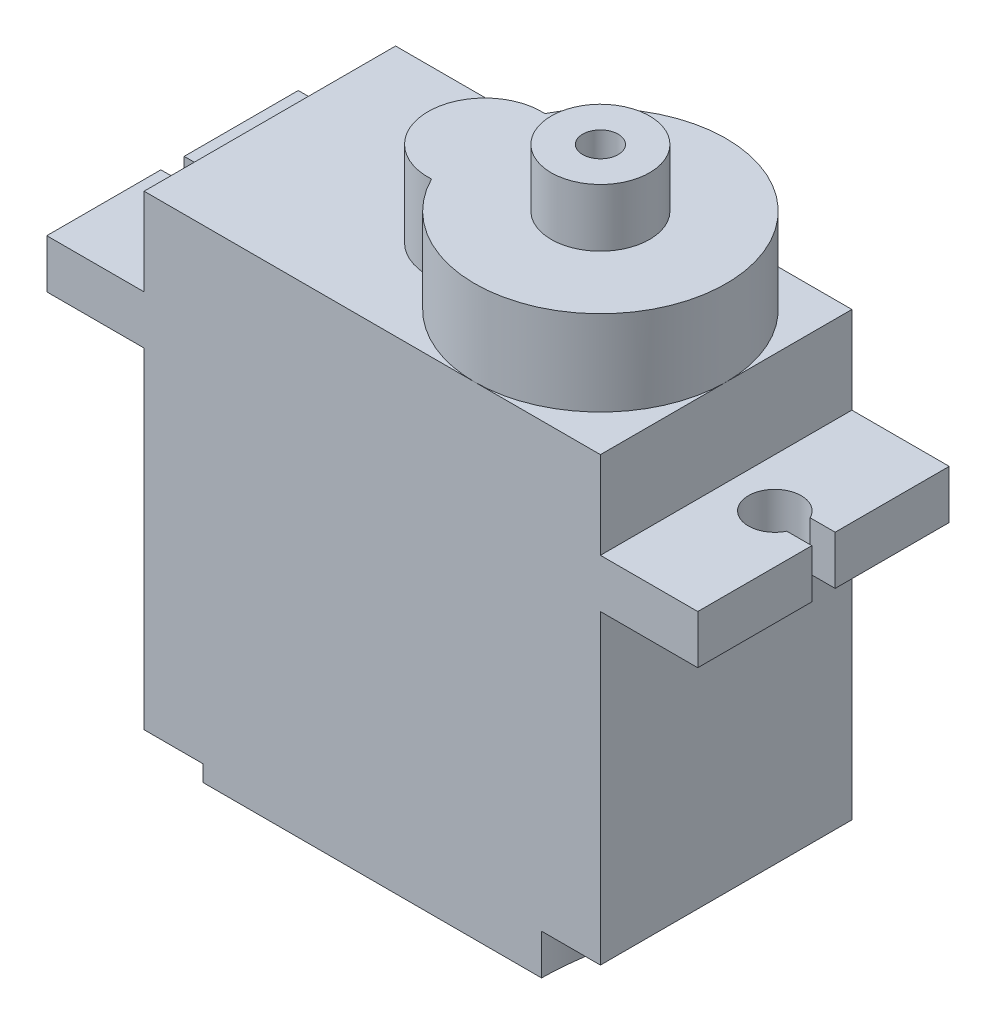
from build123d import *

# Parameters (mm, degrees)
SALIENTE_EXTRUIR1_DEPTH = 6.2
SALIENTE_EXTRUIR2_DEPTH = 4.2
CORTAR_EXTRUIR1_REACH   = 28.006
CORTAR_EXTRUIR3_DEPTH   = 0.8
CROQUIS4_5_W            = 1.5
CROQUIS4_5_H            = 3.75
CORTAR_EXTRUIR4_DEPTH   = 2
CORTAR_EXTRUIR5_DEPTH   = 26.895414652
CROQUIS7_R              = 2.425
CROQUIS7_R_2            = 0.875
SALIENTE_EXTRUIR4_DEPTH = 2.85


with BuildPart() as part:
    # Croquis1 → Saliente-Extruir1 (new, symmetric)
    with BuildSketch(Plane.XY):
        Polygon((-11.25, 5.2), (-11.25, -11.9), (11.25, -11.9), (11.25, 5.2), (16.05, 5.2), (16.05, 7.6), (11.25, 7.6), (11.25, 11.9), (-11.25, 11.9), (-11.25, 7.6), (-16.05, 7.6), (-16.05, 5.2), align=None)
    extrude(amount=SALIENTE_EXTRUIR1_DEPTH, both=True)

    # Croquis2 → Saliente-Extruir2 (add)
    with BuildSketch(Plane(origin=(0, 11.9, 0), x_dir=(1, 0, 0), z_dir=(0, 1, 0))):
        with BuildLine():
            ThreePointArc((-0.484210526, -2.79508745), (11.25, 0), (-0.484210526, 2.79508745))
            ThreePointArc((-0.484210526, 2.79508745), (-3.45, 0), (-0.484210526, -2.79508745))
        make_face()
    extrude(amount=SALIENTE_EXTRUIR2_DEPTH)

    # Croquis3 → Cortar-Extruir1 (cut, up to next)
    with BuildSketch(Plane(origin=(0, 7.6, 0), x_dir=(1, 0, 0), z_dir=(0, 1, 0)), mode=Mode.PRIVATE) as cortar_extruir1_sk1:
        with BuildLine():
            Line((16.05, 0.575), (14.815922382, 0.575))
            ThreePointArc((14.815922382, 0.575), (12.35, 0), (14.815922382, -0.575))
            Line((14.815922382, -0.575), (16.05, -0.575))
            Line((16.05, -0.575), (16.05, 0.575))
        make_face()
    cortar_extruir1_tool1 = extrude(cortar_extruir1_sk1.sketch, amount=-CORTAR_EXTRUIR1_REACH, mode=Mode.PRIVATE) & part.part
    # Croquis3 → Cortar-Extruir1 (cut, up to next)
    with BuildSketch(Plane(origin=(0, 7.6, 0), x_dir=(1, 0, 0), z_dir=(0, 1, 0)), mode=Mode.PRIVATE) as cortar_extruir1_sk2:
        with BuildLine():
            Line((-16.05, 0.575), (-14.815922382, 0.575))
            ThreePointArc((-14.815922382, 0.575), (-12.35, 0), (-14.815922382, -0.575))
            Line((-14.815922382, -0.575), (-16.05, -0.575))
            Line((-16.05, -0.575), (-16.05, 0.575))
        make_face()
    cortar_extruir1_tool2 = extrude(cortar_extruir1_sk2.sketch, amount=-CORTAR_EXTRUIR1_REACH, mode=Mode.PRIVATE) & part.part
    add(cortar_extruir1_tool1.solids().sort_by_distance((14.012834, 7.6, 0))[0], mode=Mode.SUBTRACT)
    add(cortar_extruir1_tool2.solids().sort_by_distance((-14.012834, 7.6, 0))[0], mode=Mode.SUBTRACT)

    # Croquis4 → Cortar-Extruir3 (cut)
    with BuildSketch(Plane.XZ.offset(11.9)):
        with BuildLine():
            Line((-11.25, 6.2), (-11.25, 3.3))
            ThreePointArc((-11.25, 3.3), (-9.199390335, 4.149390335), (-8.35, 6.2))
            Line((-8.35, 6.2), (-11.25, 6.2))
        make_face()
        with BuildLine():
            ThreePointArc((-8.35, -6.2), (-9.199390335, -4.149390335), (-11.25, -3.3))
            Line((-11.25, -3.3), (-11.25, -6.2))
            Line((-11.25, -6.2), (-8.35, -6.2))
        make_face()
    extrude(amount=-CORTAR_EXTRUIR3_DEPTH, mode=Mode.SUBTRACT)

    # Croquis4_5 → Cortar-Extruir4 (cut)
    with BuildSketch(Plane.XZ.offset(11.9)):
        with BuildLine():
            Line((11.25, 6.2), (8.35, 6.2))
            ThreePointArc((8.35, 6.2), (9.199390335, 4.149390335), (11.25, 3.3))
            Line((11.25, 3.3), (11.25, 6.2))
        make_face()
        with BuildLine():
            ThreePointArc((11.25, -3.3), (9.199390335, -4.149390335), (8.35, -6.2))
            Line((8.35, -6.2), (11.25, -6.2))
            Line((11.25, -6.2), (11.25, -3.3))
        make_face()
        with Locations((10.5, 0)):
            Rectangle(CROQUIS4_5_W, CROQUIS4_5_H)
    extrude(amount=-CORTAR_EXTRUIR4_DEPTH, mode=Mode.SUBTRACT)

    # Croquis6 → Cortar-Extruir5 (cut, through all)
    with BuildSketch(Plane(origin=(0, 0, -6.2), x_dir=(-1, 0, 0), z_dir=(0, 0, -1))):
        Polygon((-11.25, -9.9), (-8.35, -11.9), (-11.25, -11.9), align=None)
    extrude(amount=-CORTAR_EXTRUIR5_DEPTH, mode=Mode.SUBTRACT)

    # Croquis7 → Saliente-Extruir4 (add)
    with BuildSketch(Plane(origin=(0, 16.1, 0), x_dir=(1, 0, 0), z_dir=(0, 1, 0))):
        with Locations((5.05, 0)):
            Circle(CROQUIS7_R)
        with Locations((5.05, 0)):
            Circle(CROQUIS7_R_2, mode=Mode.SUBTRACT)
    extrude(amount=SALIENTE_EXTRUIR4_DEPTH)


solid = part.part
